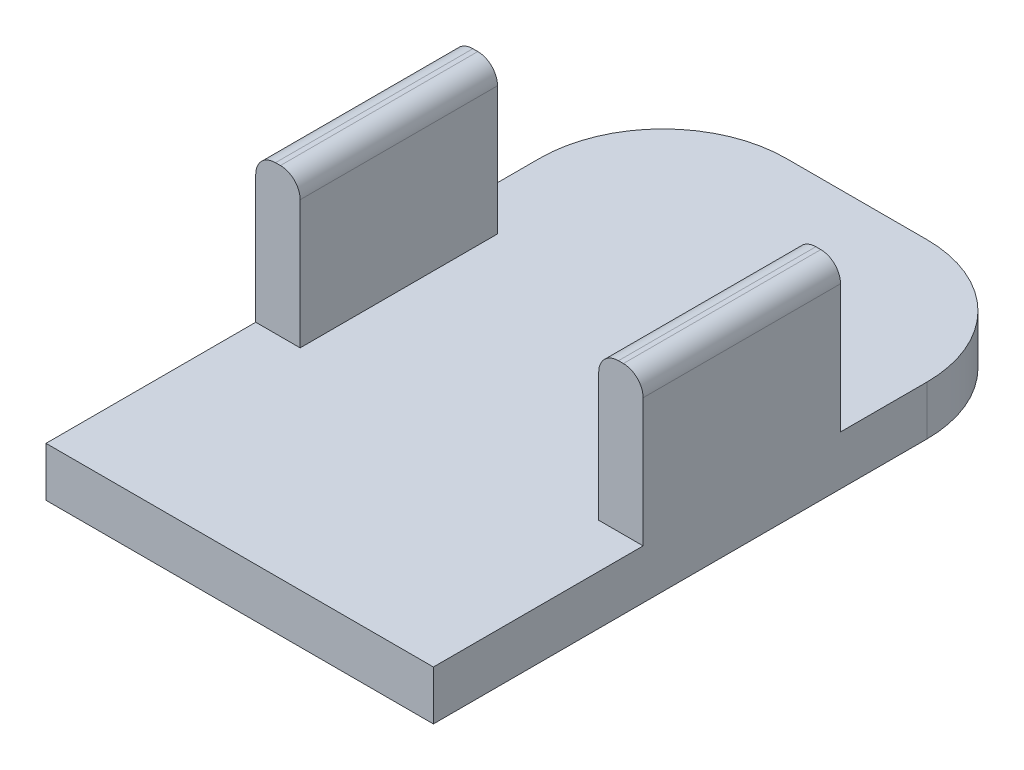
from build123d import *

# Parameters (mm, degrees)
BOSS_EXTRUDE2_DEPTH         = 5.08
SKETCH3_W                   = 4.572
SKETCH3_H                   = 20.32
BOSS_EXTRUDE3_DEPTH         = 15.24
FILLET1_R                   = 2.032
SKETCH4_W                   = 2.032
SKETCH4_H                   = 5.08
TILT_SERVO_CONNECTION_DEPTH = 12.7
SKETCH5_R                   = 0.889
CUT_EXTRUDE1_DEPTH          = 12.7
CHAMFER1_SIZE               = 5.08
CHAMFER1_SIZE2              = 1.84896879
CHAMFER1_PART_2_SIZE        = 5.08
CHAMFER1_PART_2_SIZE2       = 1.84896879


with BuildPart() as part:
    # Sketch1 → Boss-Extrude2 (new body)
    with BuildSketch(Plane(origin=(0, 0, 0), x_dir=(1, 0, 0), z_dir=(0, 1, 0))):
        with BuildLine():
            Line((-7.239, 31.75), (7.239, 31.75))
            ThreePointArc((7.239, 31.75), (16.219256121, 28.030256121), (19.939, 19.05))
            Line((19.939, 19.05), (19.939, -31.75))
            Line((19.939, -31.75), (-19.939, -31.75))
            Line((-19.939, -31.75), (-19.939, 19.05))
            ThreePointArc((-19.939, 19.05), (-16.219256121, 28.030256121), (-7.239, 31.75))
        make_face()
    extrude(amount=BOSS_EXTRUDE2_DEPTH)

    # Sketch3 → Boss-Extrude3 (add)
    with BuildSketch(Plane(origin=(0, 5.08, 0), x_dir=(1, 0, 0), z_dir=(0, 1, 0))):
        with Locations((-17.653, 0)):
            Rectangle(SKETCH3_W, SKETCH3_H)
        with Locations((17.653, 0)):
            Rectangle(SKETCH3_W, SKETCH3_H)
    extrude(amount=BOSS_EXTRUDE3_DEPTH)

    # Fillet1
    fillet1_edges = [part.edges().sort_by_distance(p)[0] for p in [
        (-19.939, 20.32, 0),
        (-15.367, 20.32, 0),
        (19.939, 20.32, 0),
        (15.367, 20.32, 0),
    ]]
    fillet(fillet1_edges, radius=FILLET1_R)

    # Sketch4 → Tilt servo connection (add)
    with BuildSketch(Plane.XZ):
        with Locations((-1.016, -29.21)):
            Rectangle(SKETCH4_W, SKETCH4_H)
    extrude(amount=TILT_SERVO_CONNECTION_DEPTH)

    # Sketch5 → Cut-Extrude1 (cut)
    with BuildSketch(Plane(origin=(0, 0, 0), x_dir=(0, 0, -1), z_dir=(1, 0, 0))):
        with Locations((29.21, -7.62)):
            Circle(SKETCH5_R)
    extrude(amount=-CUT_EXTRUDE1_DEPTH, mode=Mode.SUBTRACT)

    # Chamfer1
    chamfer1_edges = [part.edges().sort_by_distance(p)[0] for p in [
        (-1.016, -12.7, -31.75),
    ]]
    chamfer1_side = [part.faces().sort_by_distance(p)[0] for p in [
        (-0.263896104, 0.230909091, -31.75),
    ]]
    chamfer(chamfer1_edges, length=CHAMFER1_SIZE, length2=CHAMFER1_SIZE2, reference=chamfer1_side[0])

    # Chamfer1 part 2
    chamfer1_part_2_edges = [part.edges().sort_by_distance(p)[0] for p in [
        (-1.016, -12.7, -26.67),
    ]]
    chamfer1_part_2_side = [part.faces().sort_by_distance(p)[0] for p in [
        (-1.016, -6.35, -26.67),
    ]]
    chamfer(chamfer1_part_2_edges, length=CHAMFER1_PART_2_SIZE, length2=CHAMFER1_PART_2_SIZE2, reference=chamfer1_part_2_side[0])


solid = part.part
